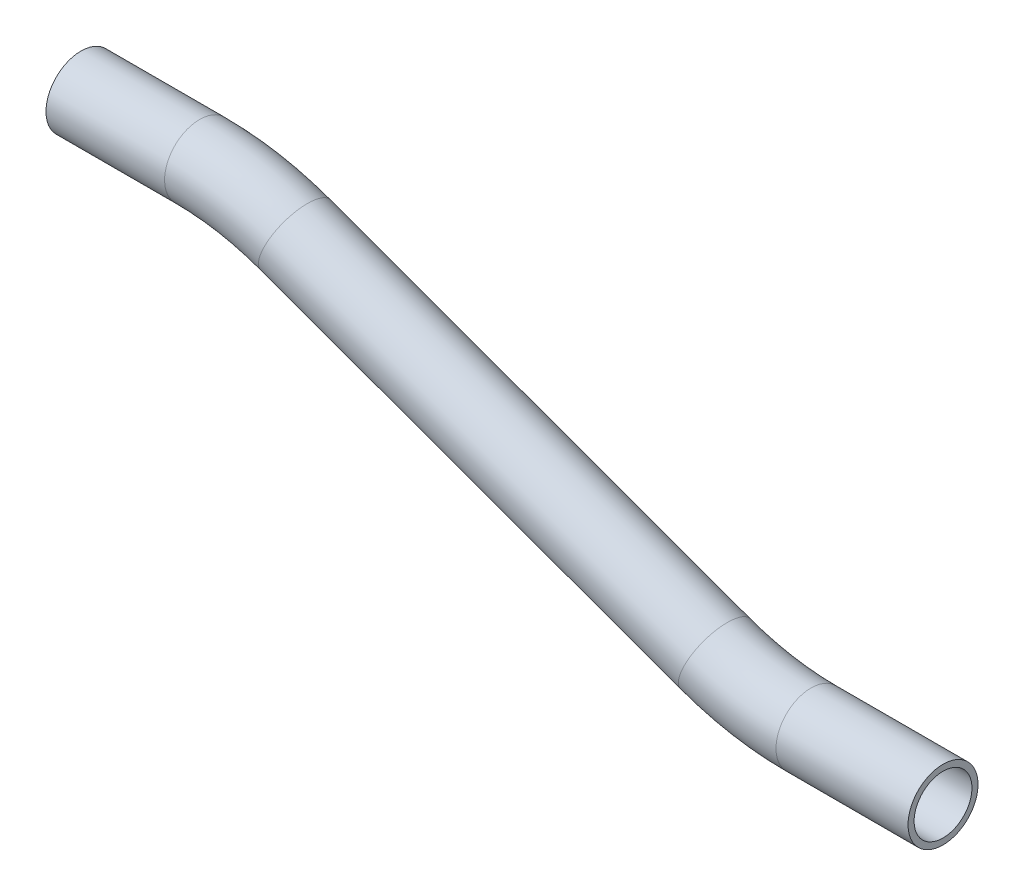
from build123d import *

# Parameters (mm, degrees)
SKETCH2_R   = 9.525
SKETCH2_R_2 = 7.874


with BuildPart() as part:
    # Sweep1: sweep along a path in Sketch1
    with BuildLine(Plane.XY) as sweep1_path:
        Line((29.832195521, -12.199967555), (62.116079591, -12.199967555))
        ThreePointArc((62.116079591, -12.199967555), (75.34807073, -13.357616776), (88.178014513, -16.795389851))
        Line((88.178014513, -16.795389851), (202.498229431, -58.404545256))
        ThreePointArc((202.498229431, -58.404545256), (215.328173214, -61.842318332), (228.560164352, -62.999967552))
        Line((228.560164352, -62.999967552), (264.501648422, -62.999967552))
    # Sketch2 → Sweep1 (sweep)
    with BuildSketch(Plane(origin=(29.832195521, -12.199967555, 0), x_dir=(0, 0, -1), z_dir=(1, 0, 0))):
        Circle(SKETCH2_R)
        Circle(SKETCH2_R_2, mode=Mode.SUBTRACT)
    sweep(path=sweep1_path.line)


solid = part.part
